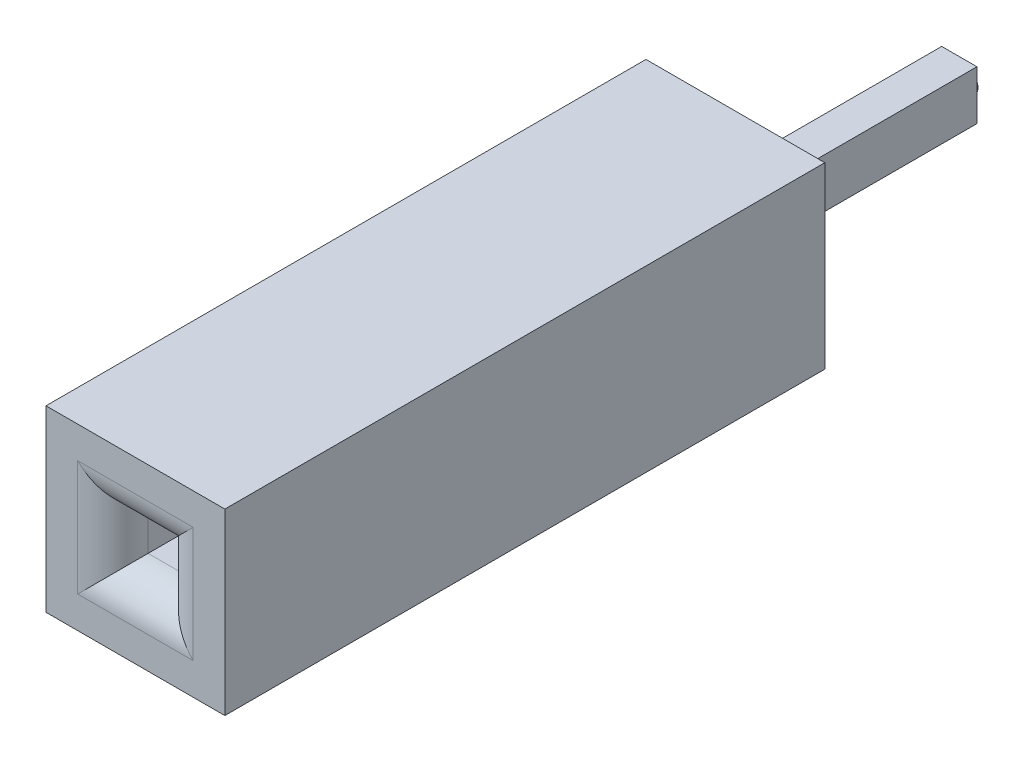
from build123d import *

# Parameters (mm, degrees)
SKETCH1_W           = 2.54
SKETCH1_H           = 2.54
BOSS_EXTRUDE1_DEPTH = 8.52
SKETCH2_W           = 0.64
SKETCH2_H           = 0.64
CUT_EXTRUDE1_DEPTH  = 6.5
FILLET1_R           = 0.5
SKETCH4_W           = 0.5
SKETCH4_H           = 0.7
BOSS_EXTRUDE2_DEPTH = 3.18
SKETCH5_R           = 0.255
CUT_EXTRUDE4_DEPTH  = 0.26
SKETCH6_R           = 0.165430126
BOSS_EXTRUDE3_DEPTH = 0.1


with BuildPart() as part:
    # Sketch1 → Boss-Extrude1 (new body)
    with BuildSketch(Plane.XY):
        Rectangle(SKETCH1_W, SKETCH1_H)
    extrude(amount=BOSS_EXTRUDE1_DEPTH)

    # Sketch2 → Cut-Extrude1 (cut)
    with BuildSketch(Plane.XY.offset(8.52)):
        Rectangle(SKETCH2_W, SKETCH2_H)
    extrude(amount=-CUT_EXTRUDE1_DEPTH, mode=Mode.SUBTRACT)

    # Fillet1
    fillet1_edges = [part.edges().sort_by_distance(p)[0] for p in [
        (0.32, 0, 8.52),
        (0, 0.32, 8.52),
        (-0.32, 0, 8.52),
        (0, -0.32, 8.52),
    ]]
    fillet(fillet1_edges, radius=FILLET1_R)

    # Sketch4 → Boss-Extrude2 (add)
    with BuildSketch(Plane(origin=(0, 0, 0), x_dir=(1, 0, 0), z_dir=(0, 0, -1))):
        Rectangle(SKETCH4_W, SKETCH4_H)
    extrude(amount=BOSS_EXTRUDE2_DEPTH)

    # Sketch5 → Cut-Extrude4 (cut)
    with BuildSketch(Plane.XY.offset(2.02)):
        Circle(SKETCH5_R)
    extrude(amount=-CUT_EXTRUDE4_DEPTH, mode=Mode.SUBTRACT)

    # Sketch6 → Boss-Extrude3 (add)
    with BuildSketch(Plane(origin=(0, 0, -3.18), x_dir=(-1, 0, 0), z_dir=(0, 0, -1))):
        Circle(SKETCH6_R)
    extrude(amount=BOSS_EXTRUDE3_DEPTH)


solid = part.part
